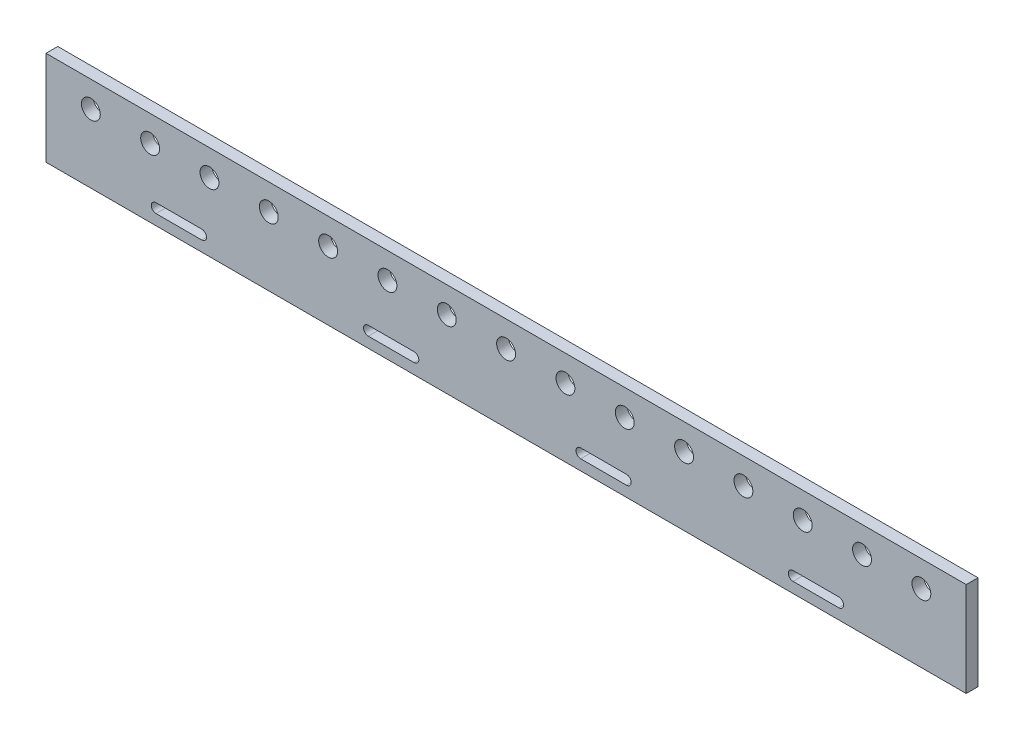
from build123d import *

# Parameters (mm, degrees)
IZIM1_W                     = 390
IZIM1_H                     = 40
IZIM1_R                     = 4
Y_KSEKLIK_EKSTR_ZYON1_DEPTH = 5
KES_EKSTR_ZYON1_DEPTH       = 90


with BuildPart() as part:
    # Çizim1 → Yükseklik-Ekstrüzyon1 (new body)
    with BuildSketch(Plane.XY):
        with Locations((-195, -20)):
            Rectangle(IZIM1_W, IZIM1_H)
        with Locations((-371, -11)):
            Circle(IZIM1_R, mode=Mode.SUBTRACT)
        with Locations((-345.857142857, -11)):
            Circle(IZIM1_R, mode=Mode.SUBTRACT)
        with Locations((-320.714285714, -11)):
            Circle(IZIM1_R, mode=Mode.SUBTRACT)
        with Locations((-295.571428571, -11)):
            Circle(IZIM1_R, mode=Mode.SUBTRACT)
        with Locations((-270.428571429, -11)):
            Circle(IZIM1_R, mode=Mode.SUBTRACT)
        with Locations((-245.285714286, -11)):
            Circle(IZIM1_R, mode=Mode.SUBTRACT)
        with Locations((-220.142857143, -11)):
            Circle(IZIM1_R, mode=Mode.SUBTRACT)
        with Locations((-195, -11)):
            Circle(IZIM1_R, mode=Mode.SUBTRACT)
        with Locations((-169.857142857, -11)):
            Circle(IZIM1_R, mode=Mode.SUBTRACT)
        with Locations((-144.714285714, -11)):
            Circle(IZIM1_R, mode=Mode.SUBTRACT)
        with Locations((-119.571428571, -11)):
            Circle(IZIM1_R, mode=Mode.SUBTRACT)
        with Locations((-94.428571429, -11)):
            Circle(IZIM1_R, mode=Mode.SUBTRACT)
        with Locations((-69.285714286, -11)):
            Circle(IZIM1_R, mode=Mode.SUBTRACT)
        with Locations((-44.142857143, -11)):
            Circle(IZIM1_R, mode=Mode.SUBTRACT)
        with Locations((-19, -11)):
            Circle(IZIM1_R, mode=Mode.SUBTRACT)
    extrude(amount=Y_KSEKLIK_EKSTR_ZYON1_DEPTH)

    # Çizim2 → Kes-Ekstrüzyon1 (cut)
    with BuildSketch(Plane.XY.offset(5)):
        with BuildLine():
            Line((-343.395447279, -31.527866379), (-323.983252141, -31.527866379))
            ThreePointArc((-323.983252141, -31.527866379), (-321.983252141, -33.527866379), (-323.983252141, -35.527866379))
            Line((-323.983252141, -35.527866379), (-343.395447279, -35.527866379))
            ThreePointArc((-343.395447279, -35.527866379), (-345.395447279, -33.527866379), (-343.395447279, -31.527866379))
        make_face()
        with BuildLine():
            Line((-253.395447279, -31.527866379), (-233.983252141, -31.527866379))
            ThreePointArc((-233.983252141, -31.527866379), (-231.983252141, -33.527866379), (-233.983252141, -35.527866379))
            Line((-233.983252141, -35.527866379), (-253.395447279, -35.527866379))
            ThreePointArc((-253.395447279, -35.527866379), (-255.395447279, -33.527866379), (-253.395447279, -31.527866379))
        make_face()
        with BuildLine():
            Line((-163.395447279, -31.527866379), (-143.983252141, -31.527866379))
            ThreePointArc((-143.983252141, -31.527866379), (-141.983252141, -33.527866379), (-143.983252141, -35.527866379))
            Line((-143.983252141, -35.527866379), (-163.395447279, -35.527866379))
            ThreePointArc((-163.395447279, -35.527866379), (-165.395447279, -33.527866379), (-163.395447279, -31.527866379))
        make_face()
        with BuildLine():
            Line((-73.395447279, -31.527866379), (-53.983252141, -31.527866379))
            ThreePointArc((-53.983252141, -31.527866379), (-51.983252141, -33.527866379), (-53.983252141, -35.527866379))
            Line((-53.983252141, -35.527866379), (-73.395447279, -35.527866379))
            ThreePointArc((-73.395447279, -35.527866379), (-75.395447279, -33.527866379), (-73.395447279, -31.527866379))
        make_face()
    extrude(amount=-KES_EKSTR_ZYON1_DEPTH, mode=Mode.SUBTRACT)


solid = part.part
